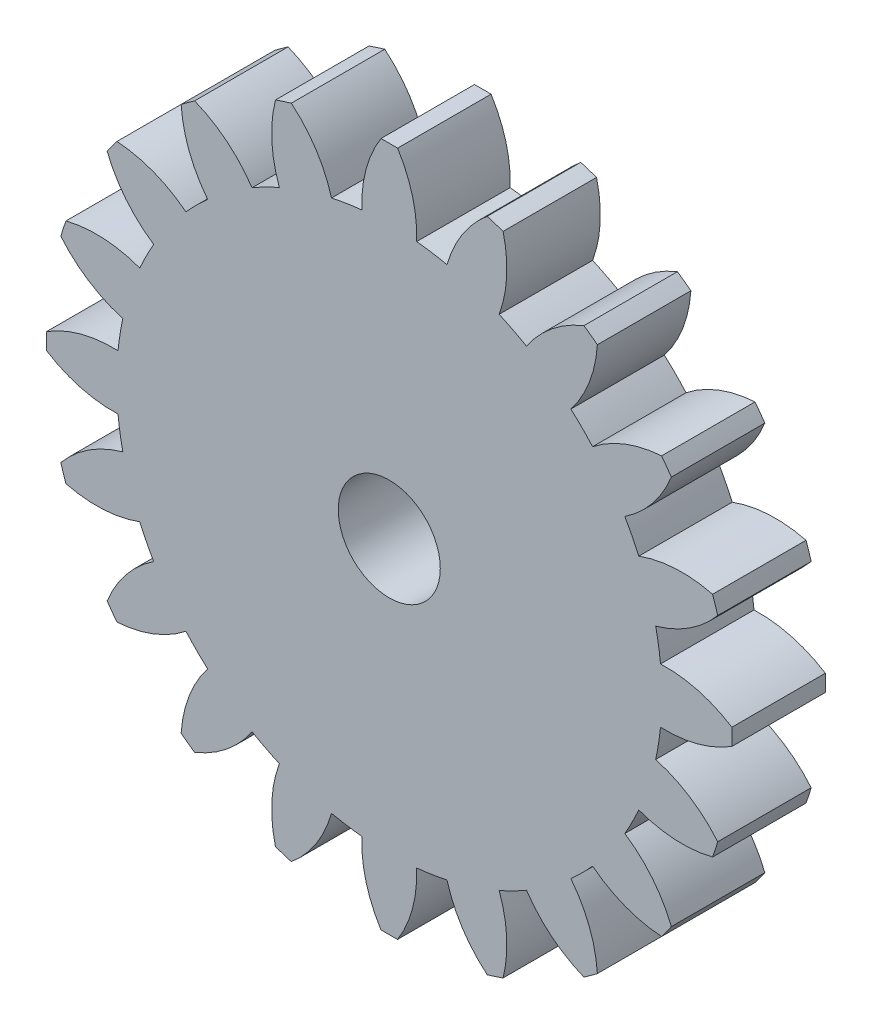
from build123d import *

# Parameters (mm, degrees)
SKETCH1_R           = 2
BOSS_EXTRUDE1_DEPTH = 6
SKETCH2_R           = 5.139196493
BOSS_EXTRUDE2_DEPTH = 6
SKETCH3_R           = 3.275
CUT_EXTRUDE1_DEPTH  = 10


with BuildPart() as part:
    # Sketch1 → Boss-Extrude1 (new body)
    with BuildSketch(Plane.XY):
        with BuildLine():
            ThreePointArc((12.495099897, 18.107249337), (10.42619144, 16.892644253), (8.810439427, 15.119231399))
            ThreePointArc((8.810439427, 15.119231399), (7.944379755, 15.591723167), (7.053068783, 16.014656467))
            ThreePointArc((7.053068783, 16.014656467), (7.538074714, 18.364213225), (7.304636989, 20.751922283))
            ThreePointArc((7.304636989, 20.751922283), (6.798373876, 20.923243358), (6.288098413, 21.082215689))
            ThreePointArc((6.288098413, 21.082215689), (4.695783155, 19.287729735), (3.707126384, 17.101819055))
            ThreePointArc((3.707126384, 17.101819055), (2.737446704, 17.283558272), (1.759066019, 17.410361505))
            ThreePointArc((1.759066019, 17.410361505), (1.494281102, 19.794797846), (0.534425957, 21.993507881))
            ThreePointArc((0.534425957, 21.993507881), (0, 22), (-0.534425957, 21.993507881))
            ThreePointArc((-0.534425957, 21.993507881), (-1.494281102, 19.794797846), (-1.759066019, 17.410361506))
            ThreePointArc((-1.759066019, 17.410361506), (-2.737446704, 17.283558272), (-3.707126384, 17.101819055))
            ThreePointArc((-3.707126384, 17.101819055), (-4.695783155, 19.287729736), (-6.288098413, 21.082215689))
            ThreePointArc((-6.288098413, 21.082215689), (-6.798373876, 20.923243359), (-7.30463699, 20.751922284))
            ThreePointArc((-7.30463699, 20.751922284), (-7.538074714, 18.364213226), (-7.053068783, 16.014656467))
            ThreePointArc((-7.053068783, 16.014656467), (-7.944379755, 15.591723167), (-8.810439427, 15.1192314))
            ThreePointArc((-8.810439427, 15.1192314), (-10.42619144, 16.892644253), (-12.495099898, 18.107249337))
            ThreePointArc((-12.495099898, 18.107249337), (-12.931275551, 17.798373876), (-13.35981926, 17.478993946))
            ThreePointArc((-13.35981926, 17.478993946), (-12.843989052, 15.136011463), (-11.656668033, 13.051325273))
            ThreePointArc((-11.656668033, 13.051325273), (-12.373661564, 12.373661564), (-13.051325273, 11.656668033))
            ThreePointArc((-13.051325273, 11.656668033), (-15.136011463, 12.843989052), (-17.478993946, 13.35981926))
            ThreePointArc((-17.478993946, 13.35981926), (-17.798373876, 12.931275551), (-18.107249337, 12.495099897))
            ThreePointArc((-18.107249337, 12.495099897), (-16.892644253, 10.42619144), (-15.1192314, 8.810439427))
            ThreePointArc((-15.1192314, 8.810439427), (-15.591723167, 7.944379755), (-16.014656467, 7.053068783))
            ThreePointArc((-16.014656467, 7.053068783), (-18.364213226, 7.538074714), (-20.751922283, 7.30463699))
            ThreePointArc((-20.751922283, 7.30463699), (-20.923243359, 6.798373876), (-21.082215689, 6.288098413))
            ThreePointArc((-21.082215689, 6.288098413), (-19.287729736, 4.695783155), (-17.101819055, 3.707126384))
            ThreePointArc((-17.101819055, 3.707126384), (-17.283558272, 2.737446704), (-17.410361505, 1.759066019))
            ThreePointArc((-17.410361505, 1.759066019), (-19.794797846, 1.494281102), (-21.993507881, 0.534425956))
            ThreePointArc((-21.993507881, 0.534425956), (-22, 0), (-21.993507881, -0.534425957))
            ThreePointArc((-21.993507881, -0.534425957), (-19.794797846, -1.494281102), (-17.410361505, -1.759066019))
            ThreePointArc((-17.410361505, -1.759066019), (-17.283558272, -2.737446704), (-17.101819055, -3.707126384))
            ThreePointArc((-17.101819055, -3.707126384), (-19.287729736, -4.695783155), (-21.082215689, -6.288098413))
            ThreePointArc((-21.082215689, -6.288098413), (-20.923243359, -6.798373876), (-20.751922283, -7.30463699))
            ThreePointArc((-20.751922283, -7.30463699), (-18.364213225, -7.538074714), (-16.014656467, -7.053068783))
            ThreePointArc((-16.014656467, -7.053068783), (-15.591723167, -7.944379755), (-15.1192314, -8.810439427))
            ThreePointArc((-15.1192314, -8.810439427), (-16.892644253, -10.42619144), (-18.107249337, -12.495099897))
            ThreePointArc((-18.107249337, -12.495099897), (-17.798373876, -12.93127555), (-17.478993946, -13.35981926))
            ThreePointArc((-17.478993946, -13.35981926), (-15.136011463, -12.843989052), (-13.051325272, -11.656668033))
            ThreePointArc((-13.051325272, -11.656668033), (-12.373661564, -12.373661564), (-11.656668033, -13.051325272))
            ThreePointArc((-11.656668033, -13.051325272), (-12.843989052, -15.136011463), (-13.35981926, -17.478993946))
            ThreePointArc((-13.35981926, -17.478993946), (-12.93127555, -17.798373876), (-12.495099897, -18.107249337))
            ThreePointArc((-12.495099897, -18.107249337), (-10.42619144, -16.892644253), (-8.810439427, -15.119231399))
            ThreePointArc((-8.810439427, -15.119231399), (-7.944379755, -15.591723167), (-7.053068783, -16.014656467))
            ThreePointArc((-7.053068783, -16.014656467), (-7.538074714, -18.364213225), (-7.304636989, -20.751922283))
            ThreePointArc((-7.304636989, -20.751922283), (-6.798373876, -20.923243358), (-6.288098413, -21.082215689))
            ThreePointArc((-6.288098413, -21.082215689), (-4.695783155, -19.287729735), (-3.707126384, -17.101819055))
            ThreePointArc((-3.707126384, -17.101819055), (-2.737446704, -17.283558272), (-1.759066019, -17.410361505))
            ThreePointArc((-1.759066019, -17.410361505), (-1.494281102, -19.794797846), (-0.534425956, -21.993507881))
            ThreePointArc((-0.534425956, -21.993507881), (0, -22), (0.534425957, -21.993507881))
            ThreePointArc((0.534425957, -21.993507881), (1.494281102, -19.794797846), (1.759066019, -17.410361505))
            ThreePointArc((1.759066019, -17.410361505), (2.737446704, -17.283558272), (3.707126384, -17.101819055))
            ThreePointArc((3.707126384, -17.101819055), (4.695783155, -19.287729735), (6.288098413, -21.082215689))
            ThreePointArc((6.288098413, -21.082215689), (6.798373876, -20.923243358), (7.304636989, -20.751922283))
            ThreePointArc((7.304636989, -20.751922283), (7.538074714, -18.364213225), (7.053068783, -16.014656467))
            ThreePointArc((7.053068783, -16.014656467), (7.944379755, -15.591723167), (8.810439427, -15.119231399))
            ThreePointArc((8.810439427, -15.119231399), (10.42619144, -16.892644253), (12.495099897, -18.107249337))
            ThreePointArc((12.495099897, -18.107249337), (12.93127555, -17.798373876), (13.359819259, -17.478993946))
            ThreePointArc((13.359819259, -17.478993946), (12.843989052, -15.136011463), (11.656668033, -13.051325272))
            ThreePointArc((11.656668033, -13.051325272), (12.373661564, -12.373661564), (13.051325272, -11.656668033))
            ThreePointArc((13.051325272, -11.656668033), (15.136011463, -12.843989052), (17.478993946, -13.35981926))
            ThreePointArc((17.478993946, -13.35981926), (17.798373876, -12.93127555), (18.107249337, -12.495099897))
            ThreePointArc((18.107249337, -12.495099897), (16.892644253, -10.42619144), (15.119231399, -8.810439427))
            ThreePointArc((15.119231399, -8.810439427), (15.591723167, -7.944379755), (16.014656467, -7.053068783))
            ThreePointArc((16.014656467, -7.053068783), (18.364213225, -7.538074714), (20.751922283, -7.304636989))
            ThreePointArc((20.751922283, -7.304636989), (20.923243358, -6.798373876), (21.082215689, -6.288098413))
            ThreePointArc((21.082215689, -6.288098413), (19.287729735, -4.695783155), (17.101819055, -3.707126384))
            ThreePointArc((17.101819055, -3.707126384), (17.283558272, -2.737446704), (17.410361505, -1.759066019))
            ThreePointArc((17.410361505, -1.759066019), (19.794797846, -1.494281102), (21.993507881, -0.534425956))
            ThreePointArc((21.993507881, -0.534425956), (22, 0), (21.993507881, 0.534425957))
            ThreePointArc((21.993507881, 0.534425957), (19.794797846, 1.494281102), (17.410361505, 1.759066019))
            ThreePointArc((17.410361505, 1.759066019), (17.283558272, 2.737446704), (17.101819055, 3.707126384))
            ThreePointArc((17.101819055, 3.707126384), (19.287729735, 4.695783155), (21.082215689, 6.288098413))
            ThreePointArc((21.082215689, 6.288098413), (20.923243358, 6.798373876), (20.751922283, 7.304636989))
            ThreePointArc((20.751922283, 7.304636989), (18.364213225, 7.538074714), (16.014656467, 7.053068783))
            ThreePointArc((16.014656467, 7.053068783), (15.591723167, 7.944379755), (15.119231399, 8.810439427))
            ThreePointArc((15.119231399, 8.810439427), (16.892644253, 10.42619144), (18.107249337, 12.495099897))
            ThreePointArc((18.107249337, 12.495099897), (17.798373876, 12.93127555), (17.478993946, 13.359819259))
            ThreePointArc((17.478993946, 13.359819259), (15.136011463, 12.843989052), (13.051325272, 11.656668033))
            ThreePointArc((13.051325272, 11.656668033), (12.373661564, 12.373661564), (11.656668033, 13.051325272))
            ThreePointArc((11.656668033, 13.051325272), (12.843989052, 15.136011463), (13.35981926, 17.478993946))
            ThreePointArc((13.35981926, 17.478993946), (12.93127555, 17.798373876), (12.495099897, 18.107249337))
        make_face()
        Circle(SKETCH1_R, mode=Mode.SUBTRACT)
    extrude(amount=BOSS_EXTRUDE1_DEPTH)

    # Sketch2 → Boss-Extrude2 (add)
    with BuildSketch(Plane.XY.offset(6)):
        Circle(SKETCH2_R)
    extrude(amount=-BOSS_EXTRUDE2_DEPTH)

    # Sketch3 → Cut-Extrude1 (cut)
    with BuildSketch(Plane.XY.offset(6)):
        Circle(SKETCH3_R)
    extrude(amount=-CUT_EXTRUDE1_DEPTH, mode=Mode.SUBTRACT)


solid = part.part
